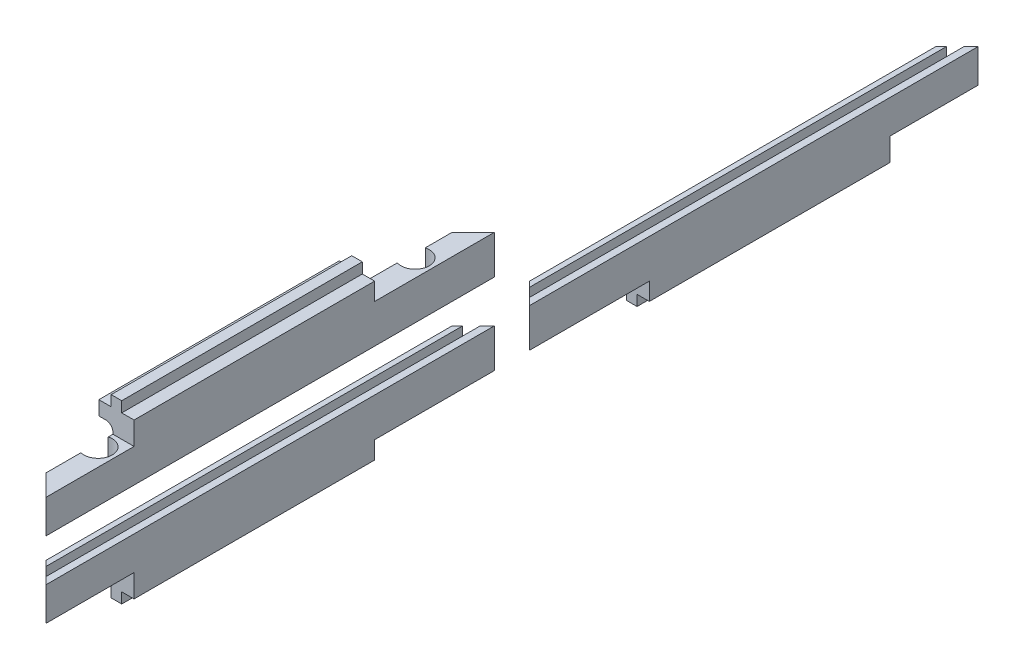
from build123d import *

# Parameters (mm, degrees)
MAIN_DEPTH                      = 127.3
CUTDIAGONALE_DEPTH              = 20
CUTOTHERPIECEINROBOTRIGHT_DEPTH = 8
CUTOTHERPIECEINROBOTLEFT_DEPTH  = 9.5
SKETCH4_R                       = 4
SCREWHOLES_DEPTH                = 8
CUT_EXTRUDE4_DEPTH              = 12
FILLET1_R                       = 2


with BuildPart() as part:
    # Sketch1 → Main (new body)
    with BuildSketch(Plane.XY):
        Polygon((-5, -3), (-1.5, -3), (-1.5, 0), (1.5, 0), (1.5, -3), (5, -3), (5, -19), (3, -19), (3, -16), (0.5, -16), (0.5, -19), (-5, -19), align=None)
    extrude(amount=MAIN_DEPTH)

    # Sketch2 → CutDiagonale (cut, through all)
    with BuildSketch(Plane(origin=(0, 0, 0), x_dir=(1, 0, 0), z_dir=(0, 1, 0))):
        Polygon((5, -127.3), (-5, -117.3), (-5, -127.3), align=None)
        Polygon((5, 0), (-5, -10), (-5, 0), align=None)
    extrude(amount=-CUTDIAGONALE_DEPTH, mode=Mode.SUBTRACT)

    # Sketch3 → CutOtherPieceInRobotRight (cut)
    with BuildSketch(Plane(origin=(0, 0, 0), x_dir=(-1, 0, 0), z_dir=(0, -1, 0))):
        Polygon((5, -10), (5, -34), (-5, -34), (-5, 0), align=None)
    extrude(amount=CUTOTHERPIECEINROBOTRIGHT_DEPTH, mode=Mode.SUBTRACT)

    # Sketch6 → CutOtherPieceInRobotLeft (cut)
    with BuildSketch(Plane(origin=(0, 0, 0), x_dir=(1, 0, 0), z_dir=(0, 1, 0))):
        Polygon((5, -127.3), (5, -102.3), (-5, -102.3), (-5, -117.3), align=None)
    extrude(amount=-CUTOTHERPIECEINROBOTLEFT_DEPTH, mode=Mode.SUBTRACT)

    # Sketch4 → ScrewHoles (cut)
    with BuildSketch(Plane(origin=(0, -8, 0), x_dir=(1, 0, 0), z_dir=(0, 1, 0))):
        with Locations((0, -17.5)):
            Circle(SKETCH4_R)
        with Locations((0, -107.5)):
            Circle(SKETCH4_R)
    extrude(amount=-SCREWHOLES_DEPTH, mode=Mode.SUBTRACT)

    # Sketch5 → Cut-Extrude4 (cut)
    with BuildSketch(Plane(origin=(0, -19, 0), x_dir=(-1, 0, 0), z_dir=(0, -1, 0))):
        Polygon((1, -121.3), (5, -117.3), (5, -10), (1, -6), align=None)
    extrude(amount=-CUT_EXTRUDE4_DEPTH, mode=Mode.SUBTRACT)

    # Fillet1
    fillet1_edges = [part.edges().sort_by_distance(p)[0] for p in [
        (-1, -7, 68.15),
    ]]
    fillet(fillet1_edges, radius=FILLET1_R)


with BuildPart() as body_2:
    # Mirror1: mirrored copy
    add(part.part.mirror(Plane.ZX.offset(-25)))


with BuildPart() as body_3:
    # Mirror2: mirrored copy
    add(body_2.part.mirror(Plane.XY.offset(-5)))


solid = Compound([part.part, body_2.part, body_3.part])
